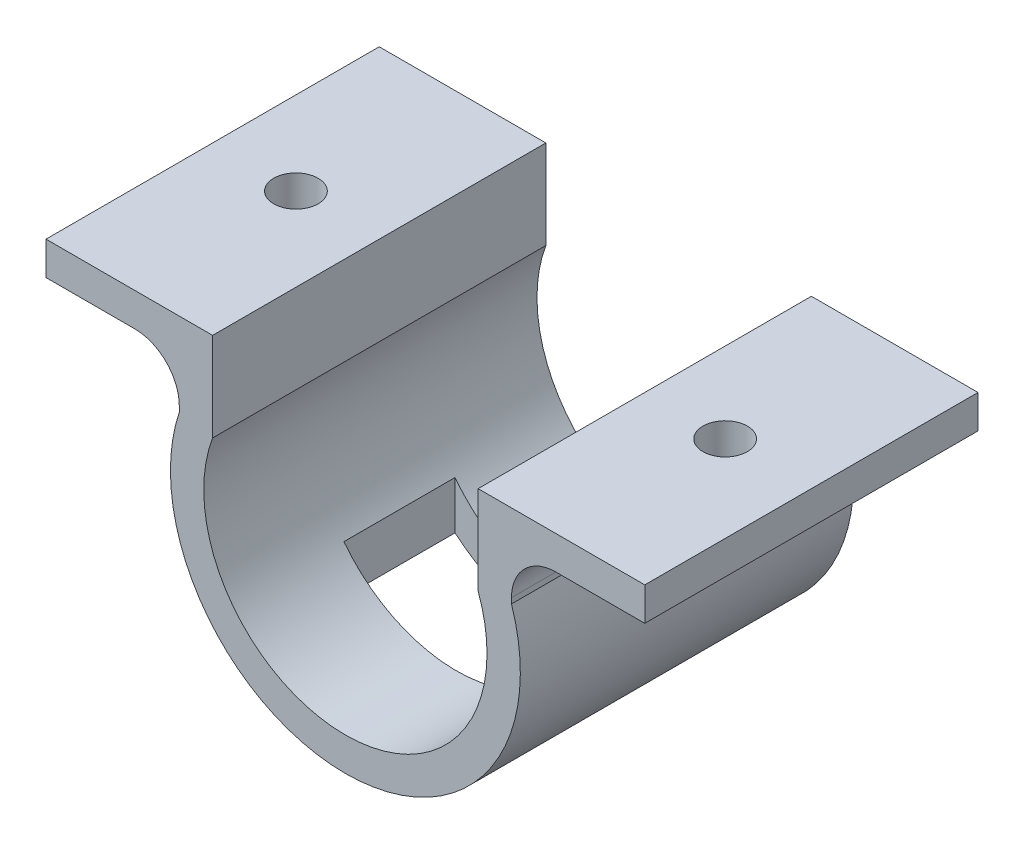
from build123d import *

# Parameters (mm, degrees)
EXTRUDE_THIN1_DEPTH = 15
FILLET1_R           = 4
SKETCH6_R           = 2
SKETCH6_W           = 20
SKETCH6_H           = 10
CUT_EXTRUDE4_DEPTH  = 29.185938934


with BuildPart() as part:
    # Sketch1 → Extrude-Thin1 (new body, symmetric)
    with BuildSketch(Plane.XY):
        with BuildLine():
            Line((27.085573469, 12.435938934), (12.085573469, 12.435938934))
            Line((12.085573469, 12.435938934), (12.085573469, 4.435938934))
            ThreePointArc((12.085573469, 4.435938934), (0.132124352, -12.75), (-11.821324764, 4.435938934))
            Line((-11.821324764, 4.435938934), (-11.821324764, 12.435938934))
            Line((-11.821324764, 12.435938934), (-26.821324764, 12.435938934))
            Line((-26.821324764, 12.435938934), (-26.821324764, 9.435938934))
            Line((-26.821324764, 9.435938934), (-14.821324764, 9.435938934))
            Line((-14.821324764, 9.435938934), (-14.821324764, 4.945387703))
            ThreePointArc((-14.821324764, 4.945387703), (0.132124352, -15.75), (15.085573469, 4.945387703))
            Line((15.085573469, 4.945387703), (15.085573469, 9.435938934))
            Line((15.085573469, 9.435938934), (27.085573469, 9.435938934))
            Line((27.085573469, 9.435938934), (27.085573469, 12.435938934))
        make_face()
    extrude(amount=EXTRUDE_THIN1_DEPTH, both=True)

    # Fillet1
    fillet1_edges = [part.edges().sort_by_distance(p)[0] for p in [
        (15.085573469, 9.435938934, 0),
        (-14.821324764, 9.435938934, 0),
    ]]
    fillet(fillet1_edges, radius=FILLET1_R)

    # Sketch6 → Cut-Extrude4 (cut, through all)
    with BuildSketch(Plane(origin=(0, 12.435938934, 0), x_dir=(1, 0, 0), z_dir=(0, 1, 0))):
        with Locations((-19.321324764, 0)):
            Circle(SKETCH6_R)
        with Locations((19.321324764, 0)):
            Circle(SKETCH6_R)
        Rectangle(SKETCH6_W, SKETCH6_H)
    extrude(amount=-CUT_EXTRUDE4_DEPTH, mode=Mode.SUBTRACT)


solid = part.part
